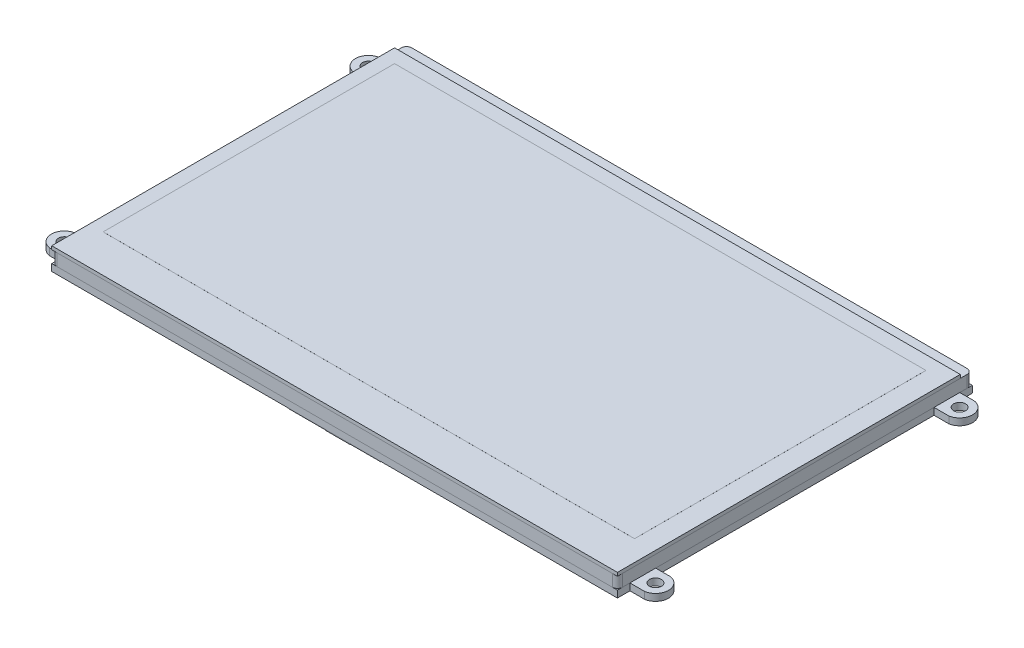
from build123d import *

# Parameters (mm, degrees)
ESQUISSE1_W        = 165
ESQUISSE1_H        = 100
BOSS_EXTRU_1_DEPTH = 1
ESQUISSE3_W        = 165
ESQUISSE3_H        = 103.5
BOSS_EXTRU_2_DEPTH = 3.5
CONG_1_R           = 1.5
ESQUISSE4_R        = 1.75
BOSS_EXTRU_3_DEPTH = 2
BOSS_EXTRU_4_DEPTH = 0.1
ESQUISSE7_W        = 25
ESQUISSE7_H        = 5.5
BOSS_EXTRU_5_DEPTH = 2
ESQUISSE9_W        = 7
ESQUISSE9_H        = 60
BOSS_EXTRU_6_DEPTH = 0.1
ESQUISSE10_W       = 13
ESQUISSE10_H       = 5
BOSS_EXTRU_8_DEPTH = 2
ESQUISSE11_W       = 155
ESQUISSE11_H       = 85
BOSS_EXTRU_9_DEPTH = 0.01


with BuildPart() as part:
    # Esquisse1 → Boss.-Extru.1 (new body)
    with BuildSketch(Plane(origin=(0, 0, 0), x_dir=(1, 0, 0), z_dir=(0, 1, 0))):
        Rectangle(ESQUISSE1_W, ESQUISSE1_H)
    extrude(amount=BOSS_EXTRU_1_DEPTH)

    # Esquisse11 → Boss.-Extru.9 (add)
    with BuildSketch(Plane(origin=(0, 1, 0), x_dir=(1, 0, 0), z_dir=(0, 1, 0))):
        with Locations((-1, 3.5)):
            Rectangle(ESQUISSE11_W, ESQUISSE11_H)
    extrude(amount=BOSS_EXTRU_9_DEPTH)


with BuildPart() as body_2:
    # Esquisse3 → Boss.-Extru.2 (new body)
    with BuildSketch(Plane.XZ):
        with Locations((0, -1.75)):
            Rectangle(ESQUISSE3_W, ESQUISSE3_H)
    extrude(amount=BOSS_EXTRU_2_DEPTH)

    # Congé1
    cong_1_edges = [body_2.edges().sort_by_distance(p)[0] for p in [
        (-82.5, -1.75, 50),
        (82.5, -1.75, 50),
        (82.5, -1.75, -53.5),
        (-82.5, -1.75, -53.5),
    ]]
    fillet(cong_1_edges, radius=CONG_1_R)


with BuildPart() as body_3:
    # Esquisse4 → Boss.-Extru.3 (new body)
    with BuildSketch(Plane.XZ.offset(3.5)):
        with BuildLine():
            Line((82.5, -53.5), (-82.5, -53.5))
            Line((-82.5, -53.5), (-82.5, -49.85))
            Line((-82.5, -49.85), (-86.814410286, -49.85))
            ThreePointArc((-86.814410286, -49.85), (-90, -46.1), (-86.814410286, -42.35))
            Line((-86.814410286, -42.35), (-82.5, -42.35))
            Line((-82.5, -42.35), (-82.5, 38.85))
            Line((-82.5, 38.85), (-86.814410286, 38.85))
            ThreePointArc((-86.814410286, 38.85), (-90, 42.6), (-86.814410286, 46.35))
            Line((-86.814410286, 46.35), (-82.5, 46.35))
            Line((-82.5, 46.35), (-82.5, 50))
            Line((-82.5, 50), (82.5, 50))
            Line((82.5, 50), (82.5, 46.35))
            Line((82.5, 46.35), (86.814410286, 46.35))
            ThreePointArc((86.814410286, 46.35), (90, 42.6), (86.814410286, 38.85))
            Line((86.814410286, 38.85), (82.5, 38.85))
            Line((82.5, 38.85), (82.5, -42.35))
            Line((82.5, -42.35), (86.814410286, -42.35))
            ThreePointArc((86.814410286, -42.35), (90, -46.1), (86.814410286, -49.85))
            Line((86.814410286, -49.85), (82.5, -49.85))
            Line((82.5, -49.85), (82.5, -53.5))
        make_face()
        with Locations((86.2, 42.6)):
            Circle(ESQUISSE4_R, mode=Mode.SUBTRACT)
        with Locations((-86.2, 42.6)):
            Circle(ESQUISSE4_R, mode=Mode.SUBTRACT)
        with Locations((-86.2, -46.1)):
            Circle(ESQUISSE4_R, mode=Mode.SUBTRACT)
        with Locations((86.2, -46.1)):
            Circle(ESQUISSE4_R, mode=Mode.SUBTRACT)
    extrude(amount=BOSS_EXTRU_3_DEPTH)


with BuildPart() as body_4:
    # Esquisse6 → Boss.-Extru.4 (new body)
    with BuildSketch(Plane.XZ.offset(5.5)):
        Polygon((13.5, 50), (13.5, 21.5), (-40.5, 21.5), (-40.5, -14), (-60.5, -14), (-60.5, 45.5), (-13.5, 45.5), (-13.5, 50), align=None)
    extrude(amount=BOSS_EXTRU_4_DEPTH)

    # Esquisse7 → Boss.-Extru.5 (add)
    with BuildSketch(Plane.XZ.offset(5.5)):
        with Locations((-50.5, -16.75)):
            Rectangle(ESQUISSE7_W, ESQUISSE7_H)
    extrude(amount=BOSS_EXTRU_5_DEPTH)

    # Esquisse9 → Boss.-Extru.6 (add)
    with BuildSketch(Plane.XZ.offset(5.6)):
        with Locations((1, 20)):
            Rectangle(ESQUISSE9_W, ESQUISSE9_H)
    extrude(amount=BOSS_EXTRU_6_DEPTH)

    # Esquisse10 → Boss.-Extru.8 (add)
    with BuildSketch(Plane.XZ.offset(5.5)):
        with Locations((1, -12.5)):
            Rectangle(ESQUISSE10_W, ESQUISSE10_H)
    extrude(amount=BOSS_EXTRU_8_DEPTH)


solid = Compound([part.part, body_2.part, body_3.part, body_4.part])
